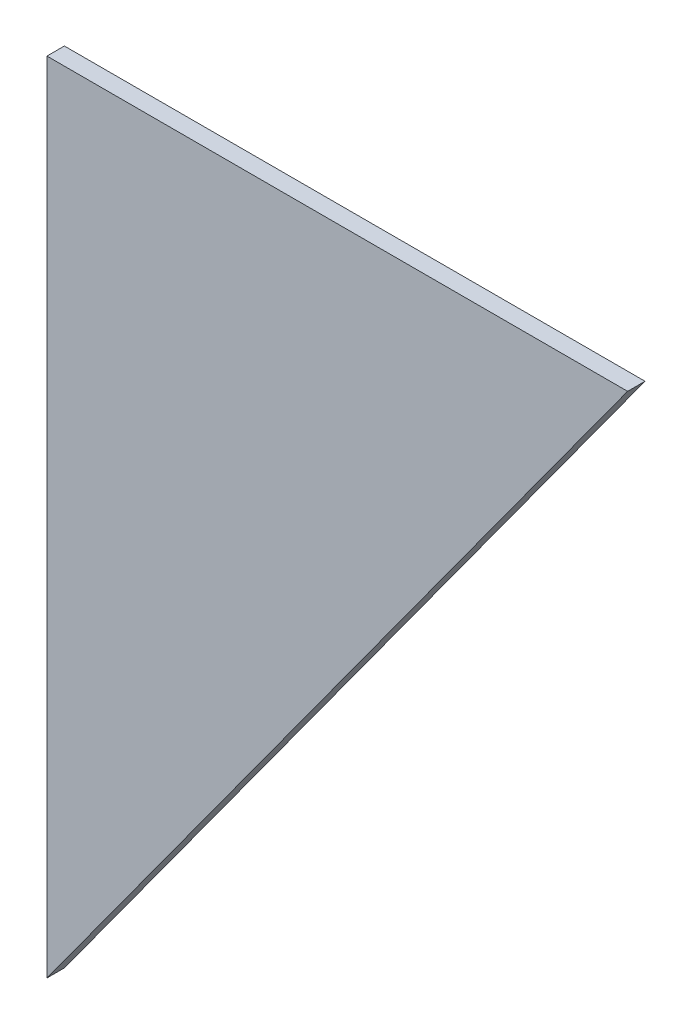
from build123d import *

# Parameters (mm, degrees)
BOSS_EXTRUDE1_DEPTH = 3.048


with BuildPart() as part:
    # Sketch1 → Boss-Extrude1 (new body)
    with BuildSketch(Plane.XY):
        Polygon((0, 0), (0, 139.7), (101.6, 139.7), align=None)
    extrude(amount=BOSS_EXTRUDE1_DEPTH)


solid = part.part
